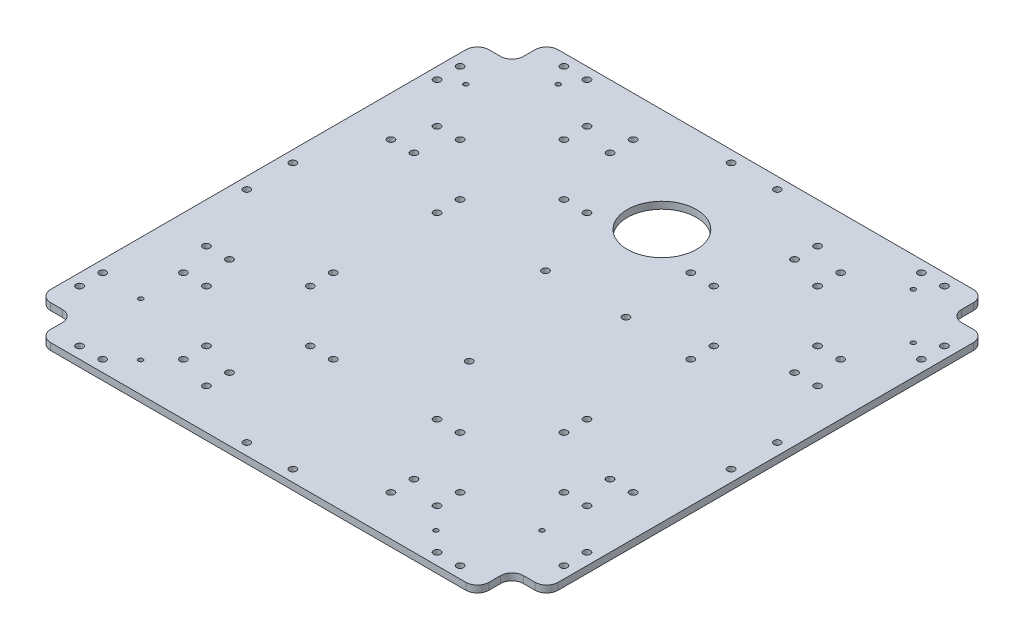
from build123d import *

# Parameters (mm, degrees)
SKETCH_1_W                 = 220
SKETCH_1_H                 = 220
SKETCH_1_R                 = 15
EXTRUDE_1_DEPTH            = 3
SKETCH_3_W                 = 15
SKETCH_3_H                 = 15
CUT_EXTRUDE_1_DEPTH        = 4
FILLET_1_R                 = 5
FILLET_2_R                 = 5
SKETCH_4_R                 = 1.5
CUT_EXTRUDE_2_DEPTH        = 4
SKETCH_6_R                 = 1.5
MTI_680G_HOLES_DEPTH       = 4
SKETCH1_R                  = 1.5
COLUMN_HOLES_DEPTH         = 4
SKETCH2_R                  = 1
LIGHTING_COVER_HOLES_DEPTH = 4
SKETCH3_R                  = 1.5
CUT_EXTRUDE3_DEPTH         = 4


with BuildPart() as part:
    # Эскиз1 → Бобышка-Вытянуть1 (new body)
    with BuildSketch(Plane(origin=(0, 0, 0), x_dir=(1, 0, 0), z_dir=(0, 1, 0))):
        Rectangle(SKETCH_1_W, SKETCH_1_H)
        with Locations((0, 65)):
            Circle(SKETCH_1_R, mode=Mode.SUBTRACT)
    extrude(amount=EXTRUDE_1_DEPTH)

    # Эскиз3 → Вырез-Вытянуть1 (cut, through all)
    with BuildSketch(Plane(origin=(0, 3, 0), x_dir=(1, 0, 0), z_dir=(0, 1, 0))):
        with Locations((102.5, 102.5)):
            Rectangle(SKETCH_3_W, SKETCH_3_H)
        with Locations((-102.5, 102.5)):
            Rectangle(SKETCH_3_W, SKETCH_3_H)
        with Locations((102.5, -102.5)):
            Rectangle(SKETCH_3_W, SKETCH_3_H)
        with Locations((-102.5, -102.5)):
            Rectangle(SKETCH_3_W, SKETCH_3_H)
    extrude(amount=-CUT_EXTRUDE_1_DEPTH, mode=Mode.SUBTRACT)

    # Скругление1
    fillet_1_edges = [part.edges().sort_by_distance(p)[0] for p in [
        (-95, 1.5, 95),
        (95, 1.5, 95),
        (95, 1.5, -95),
        (-95, 1.5, -95),
    ]]
    fillet(fillet_1_edges, radius=FILLET_1_R)

    # Скругление2
    fillet_2_edges = [part.edges().sort_by_distance(p)[0] for p in [
        (-95, 1.5, 110),
        (-110, 1.5, 95),
        (110, 1.5, 95),
        (95, 1.5, 110),
        (95, 1.5, -110),
        (110, 1.5, -95),
        (-110, 1.5, -95),
        (-95, 1.5, -110),
    ]]
    fillet(fillet_2_edges, radius=FILLET_2_R)

    # Эскиз4 → Вырез-Вытянуть2 (cut, through all)
    with BuildSketch(Plane(origin=(0, 3, 0), x_dir=(1, 0, 0), z_dir=(0, 1, 0))):
        with Locations((-82.5, 105)):
            Circle(SKETCH_4_R)
        with Locations((-72.5, 105)):
            Circle(SKETCH_4_R)
        with Locations((72.5, 105)):
            Circle(SKETCH_4_R)
        with Locations((82.5, 105)):
            Circle(SKETCH_4_R)
        with Locations((105, 82.5)):
            Circle(SKETCH_4_R)
        with Locations((105, 72.5)):
            Circle(SKETCH_4_R)
        with Locations((105, -72.5)):
            Circle(SKETCH_4_R)
        with Locations((105, -82.5)):
            Circle(SKETCH_4_R)
        with Locations((82.5, -105)):
            Circle(SKETCH_4_R)
        with Locations((72.5, -105)):
            Circle(SKETCH_4_R)
        with Locations((-72.5, -105)):
            Circle(SKETCH_4_R)
        with Locations((-82.5, -105)):
            Circle(SKETCH_4_R)
        with Locations((-105, -82.5)):
            Circle(SKETCH_4_R)
        with Locations((-105, -72.5)):
            Circle(SKETCH_4_R)
        with Locations((-105, 72.5)):
            Circle(SKETCH_4_R)
        with Locations((-105, 82.5)):
            Circle(SKETCH_4_R)
        with Locations((-10, 105)):
            Circle(SKETCH_4_R)
        with Locations((10, 105)):
            Circle(SKETCH_4_R)
        with Locations((105, 10)):
            Circle(SKETCH_4_R)
        with Locations((105, -10)):
            Circle(SKETCH_4_R)
        with Locations((10, -105)):
            Circle(SKETCH_4_R)
        with Locations((-10, -105)):
            Circle(SKETCH_4_R)
        with Locations((-105, -10)):
            Circle(SKETCH_4_R)
        with Locations((-105, 10)):
            Circle(SKETCH_4_R)
    extrude(amount=-CUT_EXTRUDE_2_DEPTH, mode=Mode.SUBTRACT)

    # Эскиз6 → MTi-680G holes (cut, through all)
    with BuildSketch(Plane(origin=(0, 3, 0), x_dir=(1, 0, 0), z_dir=(0, 1, 0))):
        with Locations((-9.75, 24.25)):
            Circle(SKETCH_6_R)
        with Locations((7.7, -26.25)):
            Circle(SKETCH_6_R)
        with Locations((25.15, 24.25)):
            Circle(SKETCH_6_R)
    extrude(amount=-MTI_680G_HOLES_DEPTH, mode=Mode.SUBTRACT)

    # Sketch1 → Column holes (cut, through all)
    with BuildSketch(Plane(origin=(0, 3, 0), x_dir=(1, 0, 0), z_dir=(0, 1, 0))):
        with Locations((-55, 32.5)):
            Circle(SKETCH1_R)
        with Locations((-55, 22.5)):
            Circle(SKETCH1_R)
        with Locations((-77.5, 55)):
            Circle(SKETCH1_R)
        with Locations((-87.5, 55)):
            Circle(SKETCH1_R)
        with Locations((-55, 77.5)):
            Circle(SKETCH1_R)
        with Locations((-55, 87.5)):
            Circle(SKETCH1_R)
        with Locations((-32.5, 55)):
            Circle(SKETCH1_R)
        with Locations((-22.5, 55)):
            Circle(SKETCH1_R)
        with Locations((32.5, 55)):
            Circle(SKETCH1_R)
        with Locations((22.5, 55)):
            Circle(SKETCH1_R)
        with Locations((55, 77.5)):
            Circle(SKETCH1_R)
        with Locations((55, 87.5)):
            Circle(SKETCH1_R)
        with Locations((77.5, 55)):
            Circle(SKETCH1_R)
        with Locations((87.5, 55)):
            Circle(SKETCH1_R)
        with Locations((55, 32.5)):
            Circle(SKETCH1_R)
        with Locations((55, 22.5)):
            Circle(SKETCH1_R)
        with Locations((55, -32.5)):
            Circle(SKETCH1_R)
        with Locations((55, -22.5)):
            Circle(SKETCH1_R)
        with Locations((77.5, -55)):
            Circle(SKETCH1_R)
        with Locations((87.5, -55)):
            Circle(SKETCH1_R)
        with Locations((55, -77.5)):
            Circle(SKETCH1_R)
        with Locations((55, -87.5)):
            Circle(SKETCH1_R)
        with Locations((32.5, -55)):
            Circle(SKETCH1_R)
        with Locations((22.5, -55)):
            Circle(SKETCH1_R)
        with Locations((-32.5, -55)):
            Circle(SKETCH1_R)
        with Locations((-22.5, -55)):
            Circle(SKETCH1_R)
        with Locations((-55, -77.5)):
            Circle(SKETCH1_R)
        with Locations((-55, -87.5)):
            Circle(SKETCH1_R)
        with Locations((-77.5, -55)):
            Circle(SKETCH1_R)
        with Locations((-87.5, -55)):
            Circle(SKETCH1_R)
        with Locations((-55, -32.5)):
            Circle(SKETCH1_R)
        with Locations((-55, -22.5)):
            Circle(SKETCH1_R)
    extrude(amount=-COLUMN_HOLES_DEPTH, mode=Mode.SUBTRACT)

    # Sketch2 → Lighting cover holes (cut, through all)
    with BuildSketch(Plane(origin=(0, 3, 0), x_dir=(1, 0, 0), z_dir=(0, 1, 0))):
        with Locations((-77, 97)):
            Circle(SKETCH2_R)
        with Locations((-97, 77)):
            Circle(SKETCH2_R)
        with Locations((77, 97)):
            Circle(SKETCH2_R)
        with Locations((97, 77)):
            Circle(SKETCH2_R)
        with Locations((-87, -74)):
            Circle(SKETCH2_R)
        with Locations((-64, -97)):
            Circle(SKETCH2_R)
        with Locations((64, -97)):
            Circle(SKETCH2_R)
        with Locations((87, -74)):
            Circle(SKETCH2_R)
    extrude(amount=-LIGHTING_COVER_HOLES_DEPTH, mode=Mode.SUBTRACT)

    # Sketch3 → Cut-Extrude3 (cut, through all)
    with BuildSketch(Plane(origin=(0, 3, 0), x_dir=(1, 0, 0), z_dir=(0, 1, 0))):
        with Locations((-40, -92.5)):
            Circle(SKETCH3_R)
        with Locations((-40, -82.5)):
            Circle(SKETCH3_R)
        with Locations((40, -82.5)):
            Circle(SKETCH3_R)
        with Locations((40, -92.5)):
            Circle(SKETCH3_R)
        with Locations((-92.5, 40)):
            Circle(SKETCH3_R)
        with Locations((-82.5, 40)):
            Circle(SKETCH3_R)
        with Locations((-82.5, -40)):
            Circle(SKETCH3_R)
        with Locations((-92.5, -40)):
            Circle(SKETCH3_R)
        with Locations((40, 92.5)):
            Circle(SKETCH3_R)
        with Locations((40, 82.5)):
            Circle(SKETCH3_R)
        with Locations((-40, 82.5)):
            Circle(SKETCH3_R)
        with Locations((-40, 92.5)):
            Circle(SKETCH3_R)
        with Locations((92.5, -40)):
            Circle(SKETCH3_R)
        with Locations((82.5, -40)):
            Circle(SKETCH3_R)
        with Locations((82.5, 40)):
            Circle(SKETCH3_R)
        with Locations((92.5, 40)):
            Circle(SKETCH3_R)
    extrude(amount=-CUT_EXTRUDE3_DEPTH, mode=Mode.SUBTRACT)


solid = part.part
